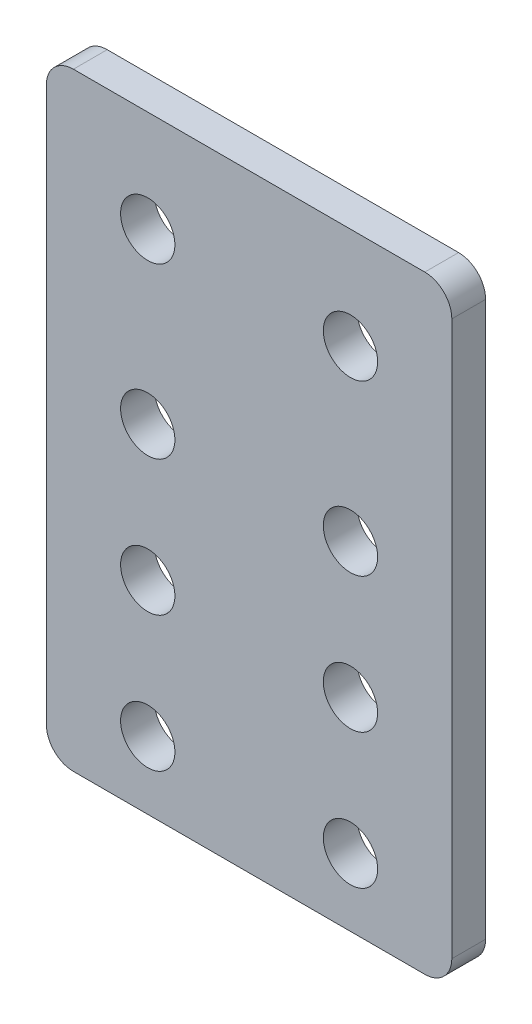
from build123d import *

# Parameters (mm, degrees)
SKETCH1_W           = 38.1
SKETCH1_H           = 57.15
SKETCH1_R           = 2.5527
BOSS_EXTRUDE1_DEPTH = 3.175
FILLET1_R           = 2.54


with BuildPart() as part:
    # Sketch1 → Boss-Extrude1 (new body)
    with BuildSketch(Plane.XY):
        Rectangle(SKETCH1_W, SKETCH1_H)
        with Locations((-9.525, 3.175)):
            Circle(SKETCH1_R, mode=Mode.SUBTRACT)
        with Locations((-9.525, 19.05)):
            Circle(SKETCH1_R, mode=Mode.SUBTRACT)
        with Locations((9.525, 3.175)):
            Circle(SKETCH1_R, mode=Mode.SUBTRACT)
        with Locations((9.525, 19.05)):
            Circle(SKETCH1_R, mode=Mode.SUBTRACT)
        with Locations((-9.525, -9.525)):
            Circle(SKETCH1_R, mode=Mode.SUBTRACT)
        with Locations((9.525, -9.525)):
            Circle(SKETCH1_R, mode=Mode.SUBTRACT)
        with Locations((-9.525, -22.225)):
            Circle(SKETCH1_R, mode=Mode.SUBTRACT)
        with Locations((9.525, -22.225)):
            Circle(SKETCH1_R, mode=Mode.SUBTRACT)
    extrude(amount=BOSS_EXTRUDE1_DEPTH)

    # Fillet1
    fillet1_edges = [part.edges().sort_by_distance(p)[0] for p in [
        (19.05, -28.575, 1.5875),
        (-19.05, -28.575, 1.5875),
        (-19.05, 28.575, 1.5875),
        (19.05, 28.575, 1.5875),
    ]]
    fillet(fillet1_edges, radius=FILLET1_R)


solid = part.part
